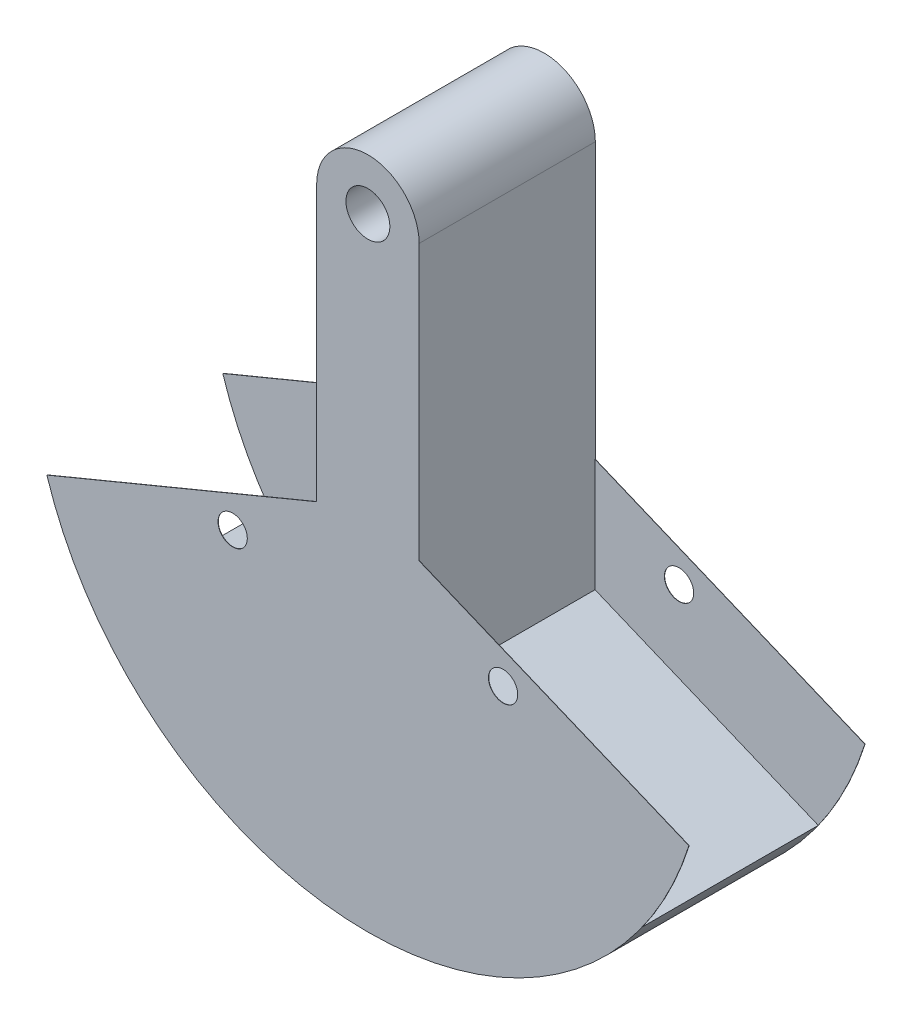
from build123d import *

# Parameters (mm, degrees)
SKETCH1_R           = 19.05
BOSS_EXTRUDE2_DEPTH = 76.2
SKETCH3_R           = 12.7
SKETCH3_R_2         = 19.05
BOSS_EXTRUDE4_DEPTH = 0.254


with BuildPart() as part:
    # Sketch1 → Boss-Extrude2 (new body, symmetric)
    with BuildSketch(Plane.XY):
        with BuildLine():
            Line((-44.45, -88.9), (-238.151556269, -169.13381166))
            ThreePointArc((-238.151556269, -169.13381166), (0, -292.1), (238.151556269, -169.13381166))
            Line((238.151556269, -169.13381166), (44.45, -88.9))
            Line((44.45, -88.9), (44.45, 247.65))
            ThreePointArc((44.45, 247.65), (0, 292.1), (-44.45, 247.65))
            Line((-44.45, 247.65), (-44.45, -88.9))
        make_face()
        with Locations((0, 247.65)):
            Circle(SKETCH1_R, mode=Mode.SUBTRACT)
    extrude(amount=BOSS_EXTRUDE2_DEPTH, both=True)

    # Sketch3 → Boss-Extrude4 (add)
    with BuildSketch(Plane.XY.offset(76.2)):
        with BuildLine():
            Line((44.45, 247.65), (44.45, 9.08096904))
            Line((44.45, 9.08096904), (278.563150245, -87.891872921))
            ThreePointArc((278.563150245, -87.891872921), (0, -292.1), (-278.563150245, -87.891872921))
            Line((-278.563150245, -87.891872921), (-44.45, 9.08096904))
            Line((-44.45, 9.08096904), (-44.45, 247.65))
            ThreePointArc((-44.45, 247.65), (0, 292.1), (44.45, 247.65))
        make_face()
        with Locations((-117.332700629, -48.60079591)):
            Circle(SKETCH3_R, mode=Mode.SUBTRACT)
        with Locations((117.332700629, -48.60079591)):
            Circle(SKETCH3_R, mode=Mode.SUBTRACT)
        with Locations((0, 247.65)):
            Circle(SKETCH3_R_2, mode=Mode.SUBTRACT)
    boss_extrude4 = extrude(amount=BOSS_EXTRUDE4_DEPTH)

    # Mirror4: Boss-Extrude4 across plane
    add(boss_extrude4.mirror(Plane.XY))


solid = part.part
